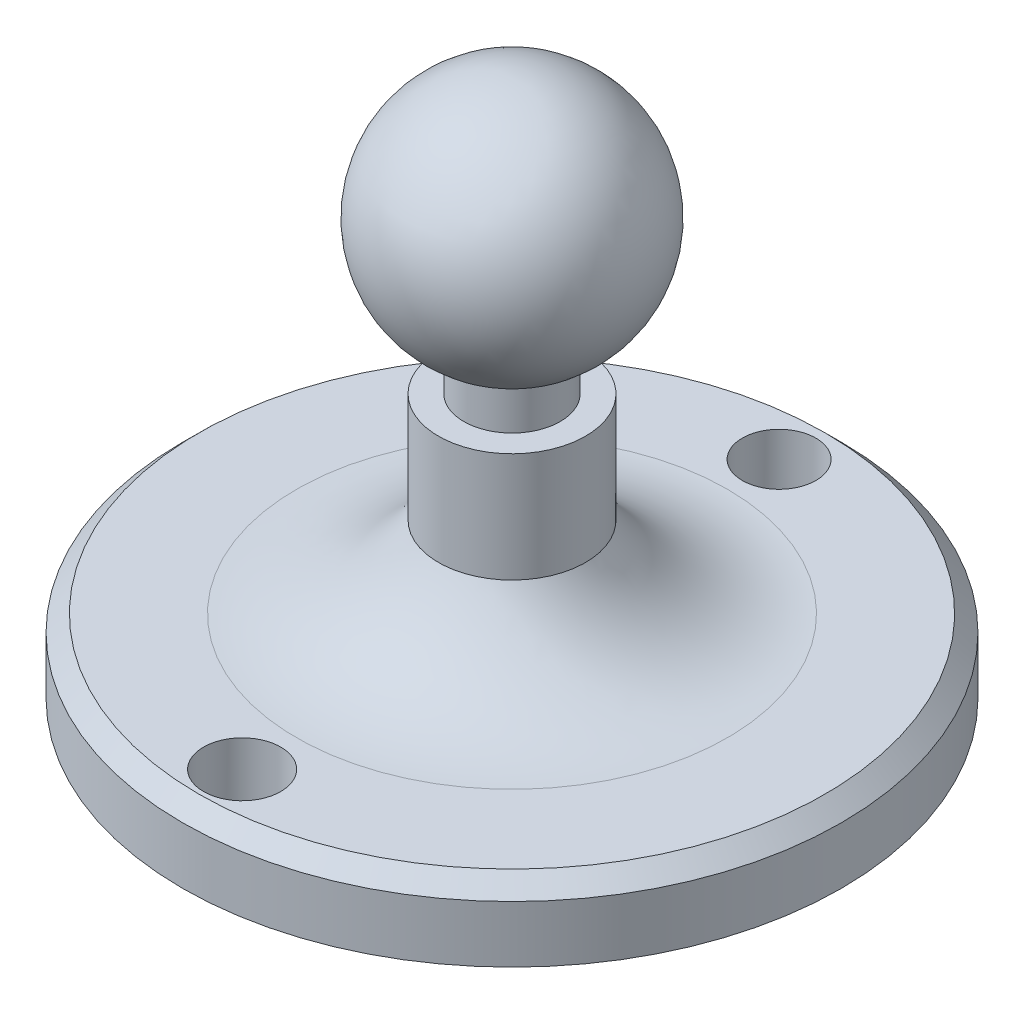
from build123d import *

# Parameters (mm, degrees)
CROQUIS2_R            = 11.708753873
CROQUIS2_R_2          = 11.163314546
CORTAR_EXTRUIR1_DEPTH = 40
CHAFL_N1_SIZE         = 5


with BuildPart() as part:
    # Croquis1 → Revolución1 (revolve)
    with BuildSketch(Plane(origin=(0, 0, 0), x_dir=(0, 0, -1), z_dir=(1, 0, 0))):
        with BuildLine():
            Line((0, 0), (100, 0))
            Line((100, 0), (100, 22.244599069))
            Line((100, 22.244599069), (65.358062391, 22.244599069))
            ThreePointArc((65.358062391, 22.244599069), (40.58262282, 28.815543652), (22.320043888, 46.801035845))
            Line((22.320043888, 46.801035845), (22.320043888, 80))
            Line((22.320043888, 80), (14.629845341, 80))
            Line((14.629845341, 80), (14.629845341, 92.520583479))
            ThreePointArc((14.629845341, 92.520583479), (35.962664377, 133.682908793), (0, 162.942316925))
            Line((0, 162.942316925), (0, 0))
        make_face()
    revolve(axis=Axis((0, 0, 0), (0, 1, 0)))

    # Croquis2 → Cortar-Extruir1 (cut)
    with BuildSketch(Plane(origin=(0, 22.244599069, 0), x_dir=(1, 0, 0), z_dir=(0, 1, 0))):
        with Locations((0, -81.89901044)):
            Circle(CROQUIS2_R)
        with Locations((0, 81.054690745)):
            Circle(CROQUIS2_R_2)
    extrude(amount=-CORTAR_EXTRUIR1_DEPTH, mode=Mode.SUBTRACT)

    # Chaflán1
    chafl_n1_edges = [part.edges().sort_by_distance(p)[0] for p in [
        (0, 22.244599069, 100),
    ]]
    chamfer(chafl_n1_edges, length=CHAFL_N1_SIZE)


solid = part.part
